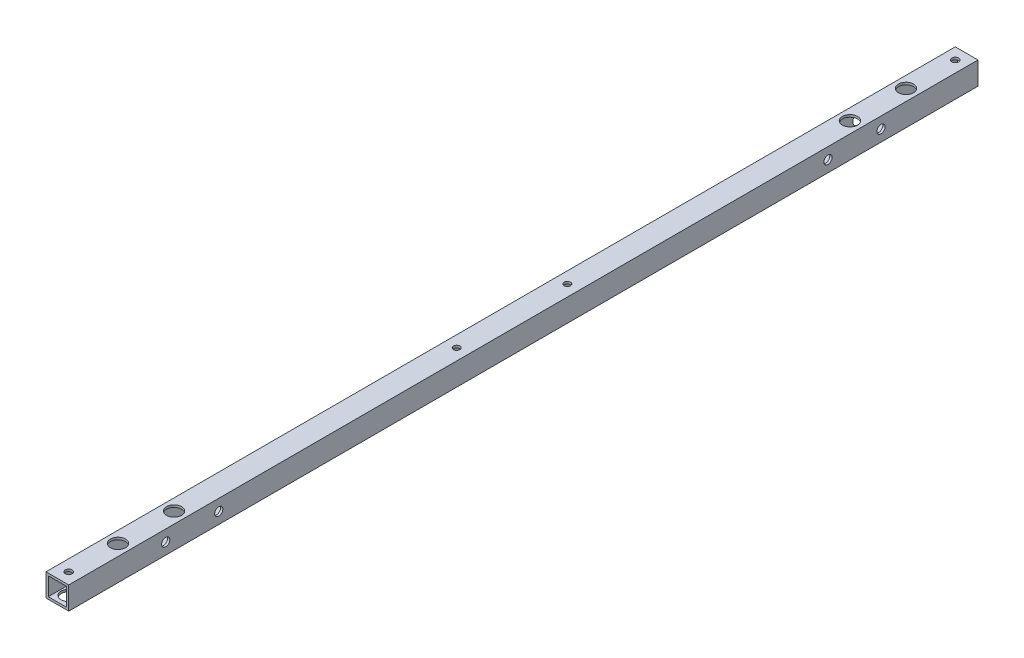
from build123d import *

# Parameters (mm, degrees)
SKETCH_1_W                  = 15
SKETCH_1_H                  = 15
SKETCH_1_W_2                = 12
SKETCH_1_H_2                = 12
EXTRUDE_1_DEPTH             = 600
SKETCH_3_R                  = 2.25
CUT_EXTRUDE_2_DEPTH         = 25
SKETCH_4_R                  = 2.7
CUT_EXTRUDE_3_DEPTH         = 20
SKETCH_6_R                  = 2.1
CUT_EXTRUDE_4_DEPTH         = 20
SKETCH_9_R                  = 5
CUT_EXTRUDE_7_DEPTH         = 10
SKETCH_10_R                 = 2.7
CUT_EXTRUDE_8_DEPTH         = 30
SKETCH_11_R                 = 5
CUT_EXTRUDE_9_DEPTH         = 10
HOLE_WIZARD_10_0_10_1_D     = 10
HOLE_WIZARD_10_0_10_1_DEPTH = 1.5


with BuildPart() as part:
    # ｽｹｯﾁ1 → ﾎﾞｽ - 押し出し1 (new body)
    with BuildSketch(Plane.XY):
        Rectangle(SKETCH_1_W, SKETCH_1_H)
        Rectangle(SKETCH_1_W_2, SKETCH_1_H_2, mode=Mode.SUBTRACT)
    extrude(amount=EXTRUDE_1_DEPTH)

    # ｽｹｯﾁ3 → ｶｯﾄ - 押し出し2 (cut)
    with BuildSketch(Plane(origin=(0, 7.5, 0), x_dir=(1, 0, 0), z_dir=(0, 1, 0))):
        with Locations((0, -7.5)):
            Circle(SKETCH_3_R)
        with Locations((0, -592.5)):
            Circle(SKETCH_3_R)
    extrude(amount=-CUT_EXTRUDE_2_DEPTH, mode=Mode.SUBTRACT)

    # ｽｹｯﾁ4 → ｶｯﾄ - 押し出し3 (cut)
    with BuildSketch(Plane(origin=(7.5, 0, 0), x_dir=(0, 0, -1), z_dir=(1, 0, 0))):
        with Locations((-536, 0)):
            Circle(SKETCH_4_R)
        with Locations((-501, 0)):
            Circle(SKETCH_4_R)
        with Locations((-99, 0)):
            Circle(SKETCH_4_R)
        with Locations((-64, 0)):
            Circle(SKETCH_4_R)
    extrude(amount=-CUT_EXTRUDE_3_DEPTH, mode=Mode.SUBTRACT)

    # ｽｹｯﾁ6 → ｶｯﾄ - 押し出し4 (cut)
    with BuildSketch(Plane(origin=(0, 7.5, 0), x_dir=(1, 0, 0), z_dir=(0, 1, 0))):
        with Locations((0, -336.5)):
            Circle(SKETCH_6_R)
        with Locations((0, -263.5)):
            Circle(SKETCH_6_R)
    extrude(amount=-CUT_EXTRUDE_4_DEPTH, mode=Mode.SUBTRACT)

    # ｽｹｯﾁ9 → ｶｯﾄ - 押し出し7 (cut)
    with BuildSketch(Plane.XZ.offset(7.5)):
        with Locations((0, 592.5)):
            Circle(SKETCH_9_R)
        with Locations((0, 336.5)):
            Circle(SKETCH_9_R)
        with Locations((0, 263.5)):
            Circle(SKETCH_9_R)
        with Locations((0, 7.5)):
            Circle(SKETCH_9_R)
    extrude(amount=-CUT_EXTRUDE_7_DEPTH, mode=Mode.SUBTRACT)

    # ｽｹｯﾁ10 → ｶｯﾄ - 押し出し8 (cut)
    with BuildSketch(Plane(origin=(0, -7.5, 0), x_dir=(-1, 0, 0), z_dir=(0, -1, 0))):
        with Locations((0, -40)):
            Circle(SKETCH_10_R)
        with Locations((0, -77)):
            Circle(SKETCH_10_R)
        with Locations((0, -523)):
            Circle(SKETCH_10_R)
        with Locations((0, -560)):
            Circle(SKETCH_10_R)
    extrude(amount=-CUT_EXTRUDE_8_DEPTH, mode=Mode.SUBTRACT)

    # ｽｹｯﾁ11 → ｶｯﾄ - 押し出し9 (cut)
    with BuildSketch(Plane(origin=(0, 7.5, 0), x_dir=(1, 0, 0), z_dir=(0, 1, 0))):
        with Locations((0, -40)):
            Circle(SKETCH_11_R)
        with Locations((0, -77)):
            Circle(SKETCH_11_R)
        with Locations((0, -560)):
            Circle(SKETCH_11_R)
        with Locations((0, -523)):
            Circle(SKETCH_11_R)
    extrude(amount=-CUT_EXTRUDE_9_DEPTH, mode=Mode.SUBTRACT)

    # Ø10.0 (10) 直径の穴1
    with Locations(Plane.ZY.offset(7.5)):
        with Locations((64, 0), (99, 0), (501, 0), (536, 0)):
            Hole(HOLE_WIZARD_10_0_10_1_D / 2, depth=HOLE_WIZARD_10_0_10_1_DEPTH)


solid = part.part
